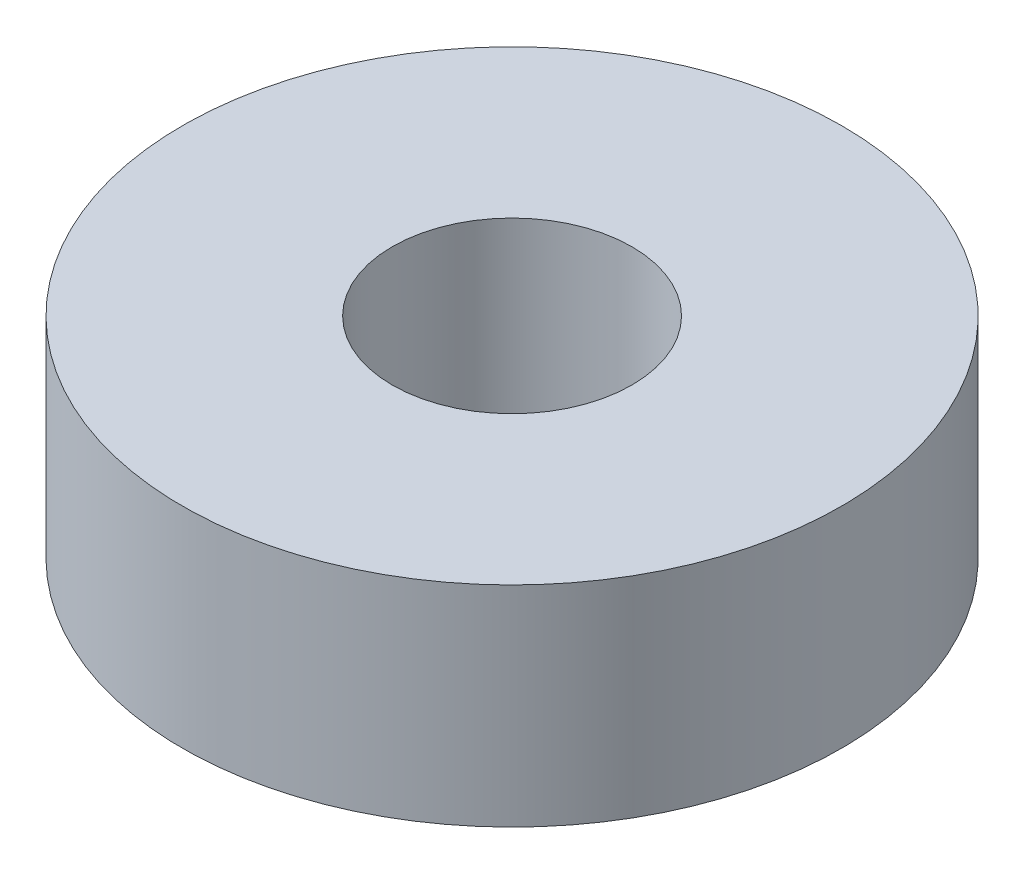
from build123d import *

# Parameters (mm, degrees)
SKETCH1_W = 7
SKETCH1_H = 7


with BuildPart() as part:
    # Sketch1 → Revolve1 (revolve)
    with BuildSketch(Plane.XY):
        with Locations((7.5, 3.5)):
            Rectangle(SKETCH1_W, SKETCH1_H)
    revolve(axis=Axis((0, 0, 0), (0, 1, 0)))


solid = part.part
